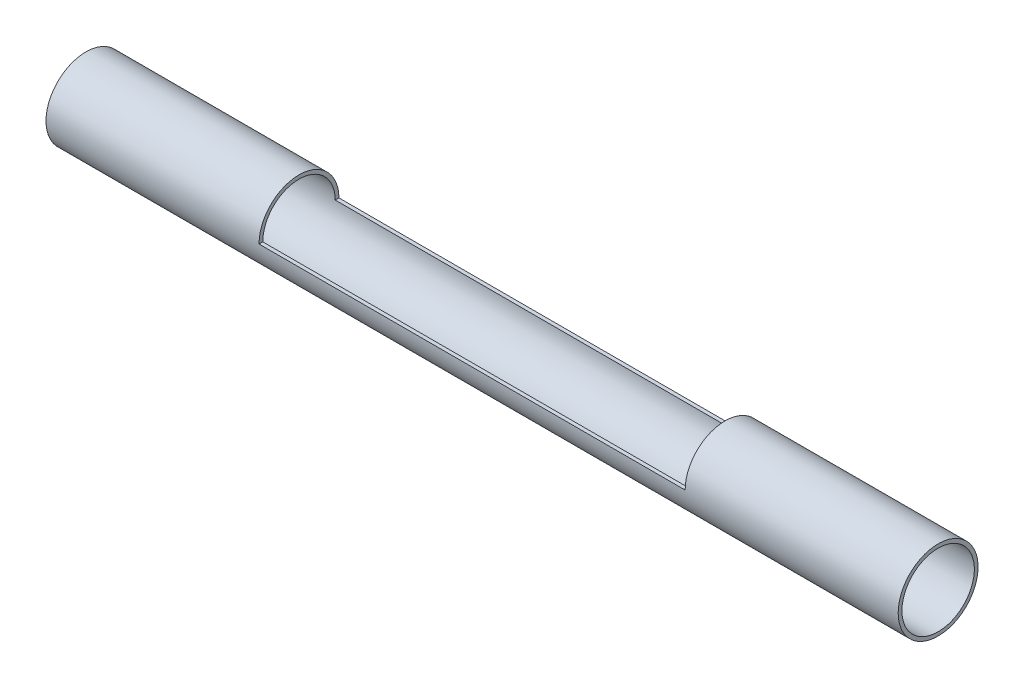
from build123d import *

# Parameters (mm, degrees)
SKETCH1_W               = 203.2
SKETCH1_H               = 0.889
SKETCH2_W               = 101.6
SKETCH2_H               = 16.721370504
CUT_EXTRUDE1_DEPTH      = 10.525
CUT_EXTRUDE1_DEPTH_BACK = 10.525


with BuildPart() as part:
    # Sketch1 → Revolve1 (revolve)
    with BuildSketch(Plane(origin=(0, 0, 0), x_dir=(1, 0, 0), z_dir=(0, 1, 0))):
        with Locations((101.6, 9.0805)):
            Rectangle(SKETCH1_W, SKETCH1_H)
    revolve(axis=Axis((0, 0, 0), (1, 0, 0)))

    # Sketch2 → Cut-Extrude1 (cut, two sides)
    with BuildSketch(Plane.XY) as cut_extrude1_sk:
        with Locations((101.6, 8.360685252)):
            Rectangle(SKETCH2_W, SKETCH2_H)
    extrude(amount=CUT_EXTRUDE1_DEPTH, mode=Mode.SUBTRACT)
    extrude(cut_extrude1_sk.sketch, amount=-CUT_EXTRUDE1_DEPTH_BACK, mode=Mode.SUBTRACT)


solid = part.part
